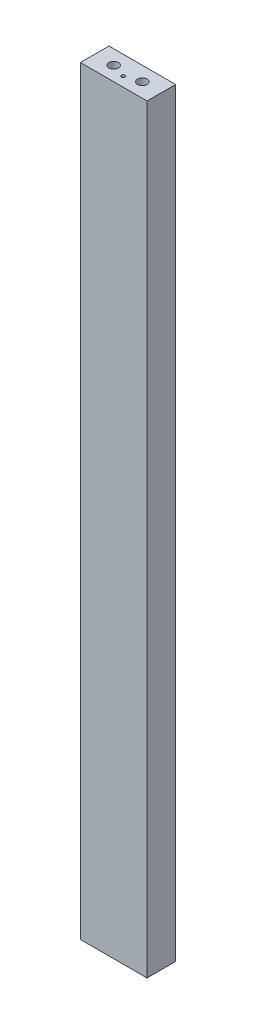
from build123d import *

# Parameters (mm, degrees)
SKETCH1_W                                  = 88.9
SKETCH1_H                                  = 38.1
BOSS_EXTRUDE1_DEPTH                        = 1012.825
SKETCH2_R                                  = 6.35
CUT_EXTRUDE1_DEPTH                         = 19.05
SKETCH3_R                                  = 6.35
CUT_EXTRUDE2_DEPTH                         = 19.05
F_10_0_1935_DIAMETER_HOLE1_D               = 4.9149
F_10_0_1935_DIAMETER_HOLE1_DEPTH           = 76.2
F_10_0_1935_DIAMETER_HOLE1_TIP             = 1.476584928
F_10_0_1935_DIAMETER_HOLE1_ON_FACE_2_D     = 4.9149
F_10_0_1935_DIAMETER_HOLE1_ON_FACE_2_DEPTH = 76.2
F_10_0_1935_DIAMETER_HOLE1_ON_FACE_2_TIP   = 1.476584928


with BuildPart() as part:
    # Sketch1 → Boss-Extrude1 (new body)
    with BuildSketch(Plane(origin=(0, 0, 0), x_dir=(1, 0, 0), z_dir=(0, 1, 0))):
        with Locations((44.45, -19.05)):
            Rectangle(SKETCH1_W, SKETCH1_H)
    extrude(amount=BOSS_EXTRUDE1_DEPTH)

    # Sketch2 → Cut-Extrude1 (cut)
    with BuildSketch(Plane(origin=(0, 1012.825, 0), x_dir=(1, 0, 0), z_dir=(0, 1, 0))):
        with Locations((25.4, -19.05)):
            Circle(SKETCH2_R)
        with Locations((63.5, -19.05)):
            Circle(SKETCH2_R)
    extrude(amount=-CUT_EXTRUDE1_DEPTH, mode=Mode.SUBTRACT)

    # Sketch3 → Cut-Extrude2 (cut)
    with BuildSketch(Plane.XZ):
        with Locations((25.4, 19.05)):
            Circle(SKETCH3_R)
        with Locations((63.5, 19.05)):
            Circle(SKETCH3_R)
    extrude(amount=-CUT_EXTRUDE2_DEPTH, mode=Mode.SUBTRACT)

    # #10 (0.1935) Diameter Hole1
    with Locations(Plane(origin=(44.45, 1012.825, 25.4), x_dir=(0, 0, 1), z_dir=(0, 1, 0))):
        with Locations((0, 0)):
            Hole(F_10_0_1935_DIAMETER_HOLE1_D / 2, depth=F_10_0_1935_DIAMETER_HOLE1_DEPTH)
            with Locations((0, 0, -(F_10_0_1935_DIAMETER_HOLE1_DEPTH + F_10_0_1935_DIAMETER_HOLE1_TIP / 2))):  # 118° drill point
                Cone(0, F_10_0_1935_DIAMETER_HOLE1_D / 2, F_10_0_1935_DIAMETER_HOLE1_TIP, mode=Mode.SUBTRACT)

    # #10 (0.1935) Diameter Hole1 on face 2
    with Locations(Plane(origin=(12.7, 0, 19.05), x_dir=(0, 0, -1), z_dir=(0, -1, 0))):
        with Locations((0, 0), (-6.35, 63.5)):
            Hole(F_10_0_1935_DIAMETER_HOLE1_ON_FACE_2_D / 2, depth=F_10_0_1935_DIAMETER_HOLE1_ON_FACE_2_DEPTH)
            with Locations((0, 0, -(F_10_0_1935_DIAMETER_HOLE1_ON_FACE_2_DEPTH + F_10_0_1935_DIAMETER_HOLE1_ON_FACE_2_TIP / 2))):  # 118° drill point
                Cone(0, F_10_0_1935_DIAMETER_HOLE1_ON_FACE_2_D / 2, F_10_0_1935_DIAMETER_HOLE1_ON_FACE_2_TIP, mode=Mode.SUBTRACT)


solid = part.part
